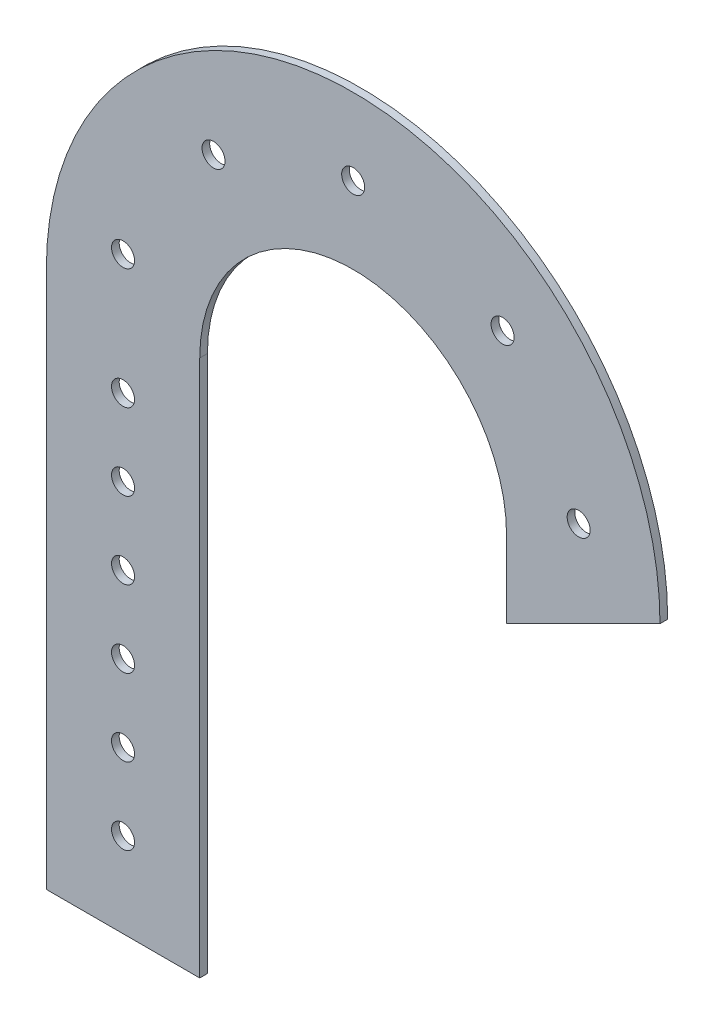
from build123d import *

# Parameters (mm, degrees)
SKETCH1_R           = 3.81
BOSS_EXTRUDE1_DEPTH = 2.54


with BuildPart() as part:
    # Sketch1 → Boss-Extrude1 (new body)
    with BuildSketch(Plane.XY):
        with BuildLine():
            Line((-101.6, 0), (-101.6, -177.8))
            Line((-101.6, -177.8), (-50.8, -177.8))
            Line((-50.8, -177.8), (-50.8, 0))
            ThreePointArc((-50.8, 0), (0, 50.8), (50.8, 0))
            Line((50.8, 0), (50.8, -25.4))
            Line((50.8, -25.4), (101.6, 0))
            ThreePointArc((101.6, 0), (0, 101.6), (-101.6, 0))
        make_face()
        with Locations((0, 76.2)):
            Circle(SKETCH1_R, mode=Mode.SUBTRACT)
        with Locations((74.66369609, 15.224075871)):
            Circle(SKETCH1_R, mode=Mode.SUBTRACT)
        with Locations((49.478172332, 57.951276627)):
            Circle(SKETCH1_R, mode=Mode.SUBTRACT)
        with Locations((-46.234392701, 60.570792727)):
            Circle(SKETCH1_R, mode=Mode.SUBTRACT)
        with Locations((-76.2, 17.081132641)):
            Circle(SKETCH1_R, mode=Mode.SUBTRACT)
        with Locations((-76.2, -22.74822838)):
            Circle(SKETCH1_R, mode=Mode.SUBTRACT)
        with Locations((-76.2, -48.14822838)):
            Circle(SKETCH1_R, mode=Mode.SUBTRACT)
        with Locations((-76.2, -73.54822838)):
            Circle(SKETCH1_R, mode=Mode.SUBTRACT)
        with Locations((-76.2, -98.94822838)):
            Circle(SKETCH1_R, mode=Mode.SUBTRACT)
        with Locations((-76.2, -124.34822838)):
            Circle(SKETCH1_R, mode=Mode.SUBTRACT)
        with Locations((-76.2, -149.74822838)):
            Circle(SKETCH1_R, mode=Mode.SUBTRACT)
    extrude(amount=BOSS_EXTRUDE1_DEPTH)


solid = part.part
